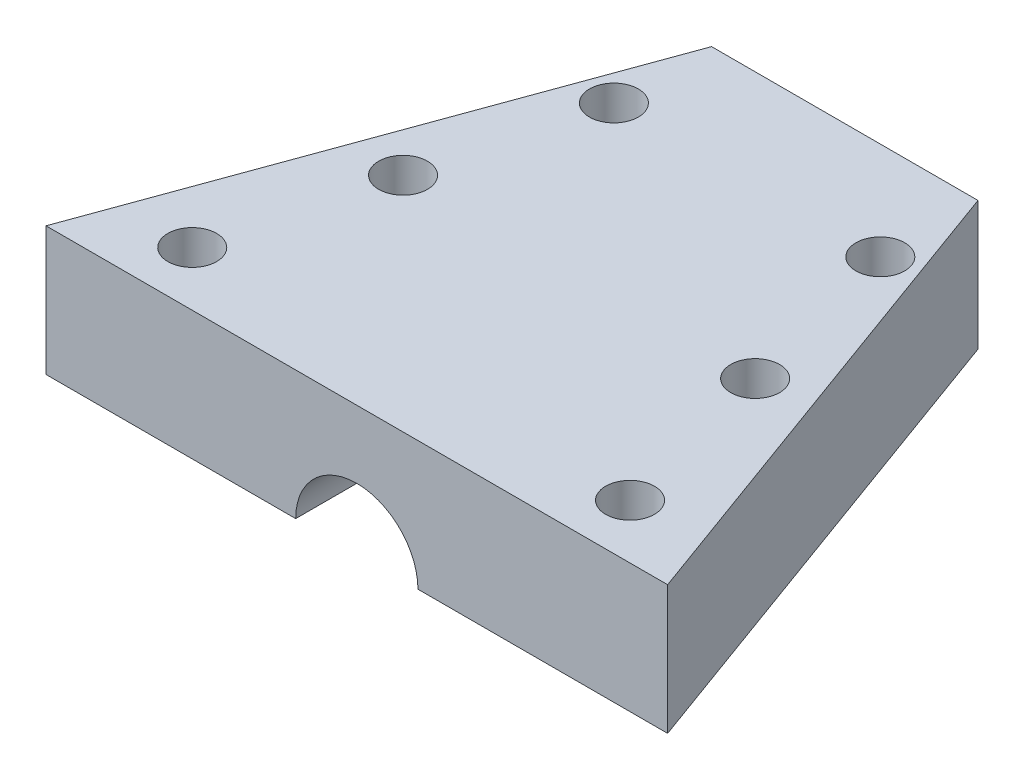
from build123d import *

# Parameters (mm, degrees)
BOSS_EXTRUDE3_DEPTH                        = 14.5
SKETCH8_R                                  = 6.884606738
CUT_EXTRUDE3_DEPTH                         = 88
F_39_0_21653543_DIAMETER_HOLE1_D           = 5.499999922
F_39_0_21653543_DIAMETER_HOLE1_ON_FACE_2_D = 5.499999922


with BuildPart() as part:
    # Sketch6 → Boss-Extrude3 (new body)
    with BuildSketch(Plane(origin=(0, 0, 0), x_dir=(1, 0, 0), z_dir=(0, 1, 0))):
        Polygon((-16.836914056, 5.783353512), (13.163085944, 5.783353512), (33.163085944, -49.166194877), (-36.836914056, -49.166194877), align=None)
    extrude(amount=BOSS_EXTRUDE3_DEPTH)

    # Sketch8 → Cut-Extrude3 (cut)
    with BuildSketch(Plane.XY.offset(49.166194877)):
        with Locations((-1.836914056, 0)):
            Circle(SKETCH8_R)
    extrude(amount=-CUT_EXTRUDE3_DEPTH, mode=Mode.SUBTRACT)

    # #39 (0.21653543) Diameter Hole1 (through all)
    with Locations(Plane(origin=(17.988085944, 14.5, 24.13287332), x_dir=(0, 0, 1), z_dir=(0, 1, 0))):
        with Locations((0, 0), (18.916226832, 4.825), (18.916226832, -44.475), (-18.916226832, -34.825), (-18.916226832, -4.825), (0, -39.65)):
            Hole(F_39_0_21653543_DIAMETER_HOLE1_D / 2)

    # #39 (0.21653543) Diameter Hole1 on face 2 (through all)
    with Locations(Plane(origin=(-16.836914056, 0, 5.216646488), x_dir=(0, 0, -1), z_dir=(0, -1, 0))):
        with Locations((0, 0), (0, 30), (-37.832453664, 39.65), (-37.832453664, -9.65)):
            Hole(F_39_0_21653543_DIAMETER_HOLE1_ON_FACE_2_D / 2)


solid = part.part
